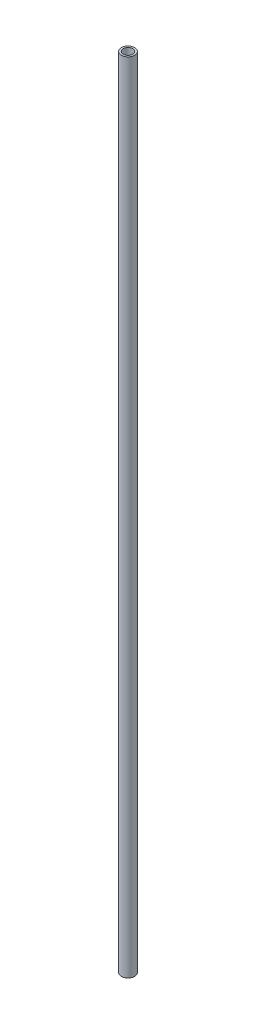
from build123d import *

# Parameters (mm, degrees)
SKETCH1_R           = 3.175
SKETCH1_R_2         = 2.286
BOSS_EXTRUDE1_DEPTH = 381


with BuildPart() as part:
    # Sketch1 → Boss-Extrude1 (new body)
    with BuildSketch(Plane(origin=(0, 0, 0), x_dir=(1, 0, 0), z_dir=(0, 1, 0))):
        Circle(SKETCH1_R)
        Circle(SKETCH1_R_2, mode=Mode.SUBTRACT)
    extrude(amount=BOSS_EXTRUDE1_DEPTH)


solid = part.part
